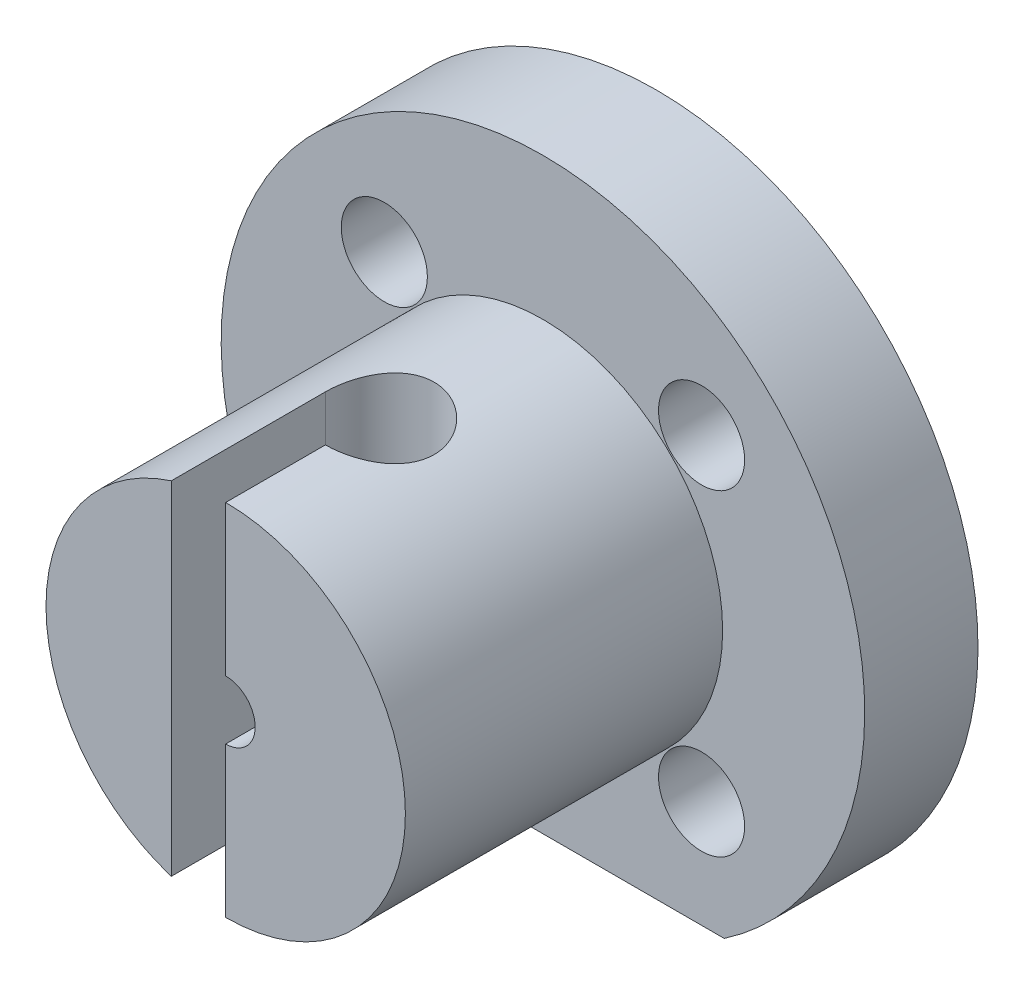
from build123d import *

# Parameters (mm, degrees)
CROQUIS1_R                 = 35.5
CROQUIS1_R_2               = 3.25
SALIENTE_EXTRUIR1_DEPTH    = 5
CROQUIS9_R                 = 19.825
CROQUIS9_R_2               = 3.25
SALIENTE_EXTRUIR4_DEPTH    = 35
CORTAR_EXTRUIR4_DEPTH      = 36.5
CORTAR_EXTRUIR4_DEPTH_BACK = 36.5
CROQUIS11_R                = 35.5
CROQUIS11_R_2              = 3.25
SALIENTE_EXTRUIR5_DEPTH    = 7.5
CORTAR_EXTRUIR5_DEPTH      = 7.5
CORTAR_EXTRUIR7_DEPTH      = 13.5
CORTAR_EXTRUIR8_REACH      = 49.5
CROQUIS16_R                = 4.75


with BuildPart() as part:
    # Croquis1 → Saliente-Extruir1 (new body)
    with BuildSketch(Plane.XY):
        Circle(CROQUIS1_R)
        Circle(CROQUIS1_R_2, mode=Mode.SUBTRACT)
    extrude(amount=SALIENTE_EXTRUIR1_DEPTH)

    # Croquis9 → Saliente-Extruir4 (add)
    with BuildSketch(Plane.XY.offset(5)):
        Circle(CROQUIS9_R)
        Circle(CROQUIS9_R_2, mode=Mode.SUBTRACT)
    extrude(amount=SALIENTE_EXTRUIR4_DEPTH)

    # Croquis10 → Cortar-Extruir4 (cut, two sides)
    with BuildSketch(Plane(origin=(0, 0, 0), x_dir=(1, 0, 0), z_dir=(0, 1, 0))) as cortar_extruir4_sk:
        with BuildLine():
            Line((0, -29), (0, -40))
            Line((0, -40), (-6, -40))
            Line((-6, -40), (-6, -23))
            ThreePointArc((-6, -23), (4.242640687, -18.757359313), (0, -29))
        make_face()
    extrude(amount=CORTAR_EXTRUIR4_DEPTH, mode=Mode.SUBTRACT)
    extrude(cortar_extruir4_sk.sketch, amount=-CORTAR_EXTRUIR4_DEPTH_BACK, mode=Mode.SUBTRACT)

    # Croquis11 → Saliente-Extruir5 (add)
    with BuildSketch(Plane(origin=(0, 0, 0), x_dir=(-1, 0, 0), z_dir=(0, 0, -1))):
        Circle(CROQUIS11_R)
        Circle(CROQUIS11_R_2, mode=Mode.SUBTRACT)
    extrude(amount=SALIENTE_EXTRUIR5_DEPTH)

    # Croquis13 → Cortar-Extruir5 (cut)
    with BuildSketch(Plane.XY.offset(5)):
        with BuildLine():
            Line((-20, -29.330018752), (20, -29.330018752))
            ThreePointArc((20, -29.330018752), (0, -35.5), (-20, -29.330018752))
        make_face()
    extrude(amount=-CORTAR_EXTRUIR5_DEPTH, mode=Mode.SUBTRACT)

    # Croquis15 → Cortar-Extruir7 (cut, through all)
    with BuildSketch(Plane.XY.offset(5)):
        with BuildLine():
            Line((20, -29.330018752), (-20, -29.330018752))
            ThreePointArc((-20, -29.330018752), (0, -35.5), (20, -29.330018752))
        make_face()
    extrude(amount=-CORTAR_EXTRUIR7_DEPTH, mode=Mode.SUBTRACT)

    # Croquis16 → Cortar-Extruir8 (cut, up to next)
    with BuildSketch(Plane(origin=(0, 0, -7.5), x_dir=(-1, 0, 0), z_dir=(0, 0, -1)), mode=Mode.PRIVATE) as cortar_extruir8_sk1:
        with Locations((17.500892834, -17.500892834)):
            Circle(CROQUIS16_R)
    cortar_extruir8_tool1 = extrude(cortar_extruir8_sk1.sketch, amount=-CORTAR_EXTRUIR8_REACH, mode=Mode.PRIVATE) & part.part
    add(cortar_extruir8_tool1.solids().sort_by_distance((-17.500893, -17.500893, -7.5))[0], mode=Mode.SUBTRACT)
    # Croquis16 → Cortar-Extruir8 (cut, up to next)
    with BuildSketch(Plane(origin=(0, 0, -7.5), x_dir=(-1, 0, 0), z_dir=(0, 0, -1)), mode=Mode.PRIVATE) as cortar_extruir8_sk2:
        with Locations((-17.500892834, -17.500892834)):
            Circle(CROQUIS16_R)
    cortar_extruir8_tool2 = extrude(cortar_extruir8_sk2.sketch, amount=-CORTAR_EXTRUIR8_REACH, mode=Mode.PRIVATE) & part.part
    add(cortar_extruir8_tool2.solids().sort_by_distance((17.500893, -17.500893, -7.5))[0], mode=Mode.SUBTRACT)
    # Croquis16 → Cortar-Extruir8 (cut, up to next)
    with BuildSketch(Plane(origin=(0, 0, -7.5), x_dir=(-1, 0, 0), z_dir=(0, 0, -1)), mode=Mode.PRIVATE) as cortar_extruir8_sk3:
        with Locations((-17.500892834, 17.500892834)):
            Circle(CROQUIS16_R)
    cortar_extruir8_tool3 = extrude(cortar_extruir8_sk3.sketch, amount=-CORTAR_EXTRUIR8_REACH, mode=Mode.PRIVATE) & part.part
    add(cortar_extruir8_tool3.solids().sort_by_distance((17.500893, 17.500893, -7.5))[0], mode=Mode.SUBTRACT)
    # Croquis16 → Cortar-Extruir8 (cut, up to next)
    with BuildSketch(Plane(origin=(0, 0, -7.5), x_dir=(-1, 0, 0), z_dir=(0, 0, -1)), mode=Mode.PRIVATE) as cortar_extruir8_sk4:
        with Locations((17.500892834, 17.500892834)):
            Circle(CROQUIS16_R)
    cortar_extruir8_tool4 = extrude(cortar_extruir8_sk4.sketch, amount=-CORTAR_EXTRUIR8_REACH, mode=Mode.PRIVATE) & part.part
    add(cortar_extruir8_tool4.solids().sort_by_distance((-17.500893, 17.500893, -7.5))[0], mode=Mode.SUBTRACT)


solid = part.part
